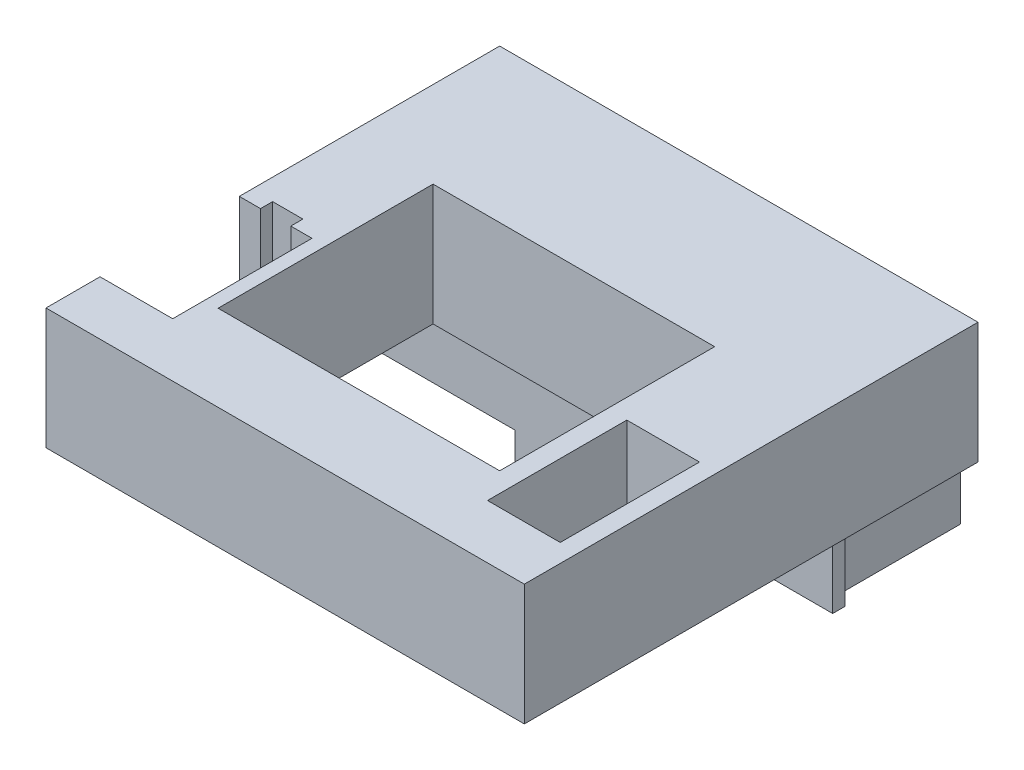
from build123d import *

# Parameters (mm, degrees)
CROQUIS1_W              = 78.999998048
CROQUIS1_H              = 74.927002192
SALIENTE_EXTRUIR1_DEPTH = 20.000000019
SALIENTE_EXTRUIR2_DEPTH = 10.311999824
CROQUIS3_W              = 75.000999496
CROQUIS3_H              = 2.000000328
SALIENTE_EXTRUIR3_DEPTH = 8.357999846
CROQUIS4_W              = 24.49000068
CROQUIS4_H              = 6.999999285
CORTAR_EXTRUIR1_DEPTH   = 22.999999881
CROQUIS5_W              = 22.500999272
CROQUIS5_H              = 6.999999285
CORTAR_EXTRUIR2_DEPTH   = 22.999999881
CROQUIS6_W              = 12.001998722
CROQUIS6_H              = 23.004993797
CORTAR_EXTRUIR3_DEPTH   = 21.000000019
CROQUIS7_W              = 24.414002895
CROQUIS7_H              = 6.024999544
SALIENTE_EXTRUIR4_DEPTH = 19.999999553
CROQUIS8_W              = 46.50499858
CROQUIS8_H              = 35.505000502
CORTAR_EXTRUIR4_DEPTH   = 39.669999689
CROQUIS9_W              = 12.004999444
CROQUIS9_H              = 23.004993797
CORTAR_EXTRUIR5_DEPTH   = 21.000000019
CROQUIS10_W             = 15.239998699
CROQUIS10_H             = 15.390999034
CORTAR_EXTRUIR6_DEPTH   = 35.069999285
CROQUIS11_W             = 20.498998463
CROQUIS11_H             = 13.852000004
CORTAR_EXTRUIR7_DEPTH   = 10.311999824
CROQUIS12_W             = 20.499996841
CROQUIS12_H             = 13.852000004
CORTAR_EXTRUIR8_DEPTH   = 10.311999824
CROQUIS13_W             = 5
CROQUIS13_H             = 10
CORTAR_EXTRUIR9_DEPTH   = 2


with BuildPart() as part:
    # Croquis1 → Saliente-Extruir1 (new body)
    with BuildSketch(Plane(origin=(0, 13.269999996, 0), x_dir=(1, 0, 0), z_dir=(0, 1, 0))):
        with Locations((-51.499999128, -37.463501096)):
            Rectangle(CROQUIS1_W, CROQUIS1_H)
    extrude(amount=-SALIENTE_EXTRUIR1_DEPTH)

    # Croquis2 → Saliente-Extruir2 (add)
    with BuildSketch(Plane.XZ.offset(6.730000023)):
        Polygon((-14.878999442, 0), (-88.121004403, 0), (-88.121004403, 19.999999553), (-89.000999928, 19.999999553), (-89.000999928, 21.999999881), (-14.000000432, 21.999999881), (-14.000000432, 19.999999553), (-14.878999442, 19.999999553), align=None)
    extrude(amount=SALIENTE_EXTRUIR2_DEPTH)

    # Croquis3 → Saliente-Extruir3 (add)
    with BuildSketch(Plane.XZ.offset(17.041999847)):
        with Locations((-51.50050018, 20.999999717)):
            Rectangle(CROQUIS3_W, CROQUIS3_H)
    extrude(amount=SALIENTE_EXTRUIR3_DEPTH)

    # Croquis4 → Cortar-Extruir1 (cut, through all)
    with BuildSketch(Plane.XY.offset(21.999999881)):
        with Locations((-26.245000772, -21.900000051)):
            Rectangle(CROQUIS4_W, CROQUIS4_H)
    extrude(amount=-CORTAR_EXTRUIR1_DEPTH, mode=Mode.SUBTRACT)

    # Croquis5 → Cortar-Extruir2 (cut, through all)
    with BuildSketch(Plane.XY.offset(21.999999881)):
        with Locations((-77.750500292, -21.900000051)):
            Rectangle(CROQUIS5_W, CROQUIS5_H)
    extrude(amount=-CORTAR_EXTRUIR2_DEPTH, mode=Mode.SUBTRACT)

    # Croquis6 → Cortar-Extruir3 (cut, through all)
    with BuildSketch(Plane.XZ.offset(6.730000023)):
        with Locations((-84.998998791, 54.500497878)):
            Rectangle(CROQUIS6_W, CROQUIS6_H)
    extrude(amount=-CORTAR_EXTRUIR3_DEPTH, mode=Mode.SUBTRACT)

    # Croquis7 → Saliente-Extruir4 (add)
    with BuildSketch(Plane(origin=(0, 0, 19.999999553), x_dir=(-1, 0, 0), z_dir=(0, 0, -1))):
        with Locations((51.50000006, -20.054499619)):
            Rectangle(CROQUIS7_W, CROQUIS7_H)
    extrude(amount=SALIENTE_EXTRUIR4_DEPTH)

    # Croquis8 → Cortar-Extruir4 (cut, through all)
    with BuildSketch(Plane(origin=(0, 13.269999996, 0), x_dir=(-1, 0, 0), z_dir=(0, 1, 0))):
        with Locations((53.500498645, 43.000498787)):
            Rectangle(CROQUIS8_W, CROQUIS8_H)
    extrude(amount=-CORTAR_EXTRUIR4_DEPTH, mode=Mode.SUBTRACT)

    # Croquis9 → Cortar-Extruir5 (cut, through all)
    with BuildSketch(Plane.XZ.offset(6.730000023)):
        with Locations((-21.000499837, 54.500497878)):
            Rectangle(CROQUIS9_W, CROQUIS9_H)
    extrude(amount=-CORTAR_EXTRUIR5_DEPTH, mode=Mode.SUBTRACT)

    # Croquis10 → Cortar-Extruir6 (cut)
    with BuildSketch(Plane.XZ.offset(23.066999391)):
        with Locations((-51.50000006, 9.319499426)):
            Rectangle(CROQUIS10_W, CROQUIS10_H)
    extrude(amount=-CORTAR_EXTRUIR6_DEPTH, mode=Mode.SUBTRACT)

    # Croquis11 → Cortar-Extruir7 (cut)
    with BuildSketch(Plane.XZ.offset(17.041999847)):
        with Locations((-27.585498988, 9.999999893)):
            Rectangle(CROQUIS11_W, CROQUIS11_H)
    extrude(amount=-CORTAR_EXTRUIR7_DEPTH, mode=Mode.SUBTRACT)

    # Croquis12 → Cortar-Extruir8 (cut)
    with BuildSketch(Plane.XZ.offset(17.041999847)):
        with Locations((-75.486000628, 9.999999893)):
            Rectangle(CROQUIS12_W, CROQUIS12_H)
    extrude(amount=-CORTAR_EXTRUIR8_DEPTH, mode=Mode.SUBTRACT)

    # Croquis13 → Cortar-Extruir9 (cut)
    with BuildSketch(Plane.XY.offset(42.998000979)):
        with Locations((-84.999998152, 8.269999996)):
            Rectangle(CROQUIS13_W, CROQUIS13_H)
    extrude(amount=-CORTAR_EXTRUIR9_DEPTH, mode=Mode.SUBTRACT)


solid = part.part
